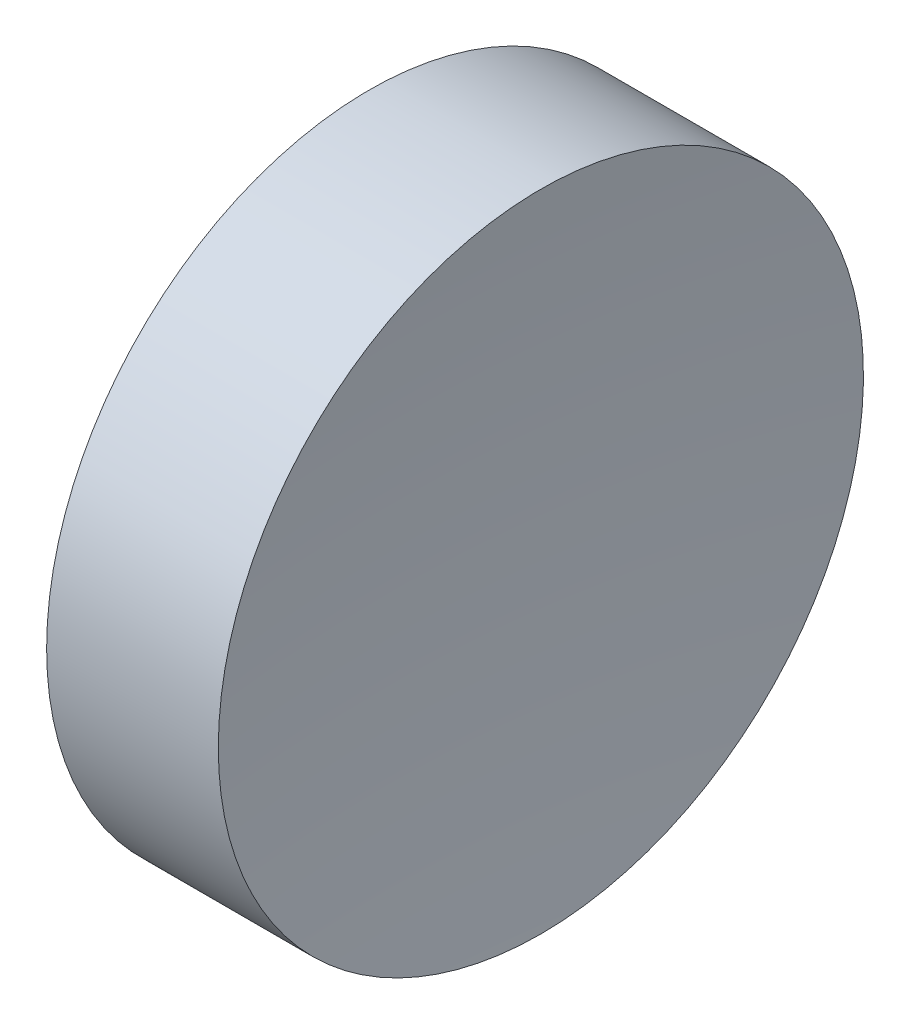
from build123d import *


with BuildPart() as part:
    # 草图1 → 旋转1 (revolve)
    with BuildSketch(Plane.XY, mode=Mode.PRIVATE) as revolve_1_sk:
        with BuildLine():
            Line((57.546327767, 34.689010562), (57.546327767, 40.939010562))
            Line((57.546327767, 40.939010562), (60.872736291, 40.939010562))
            ThreePointArc((60.872736291, 40.939010562), (60.627985341, 37.818269365), (60.546327602, 34.689010562))
            Line((60.546327602, 34.689010562), (57.546327767, 34.689010562))
        make_face()
    revolve(revolve_1_sk.sketch.rotate(Axis((54.492571501, 34.689010562, 0), (1, 0, 0)), 180), axis=Axis((54.492571501, 34.689010562, 0), (1, 0, 0)))  # turned: the seam where the file's is


solid = part.part
